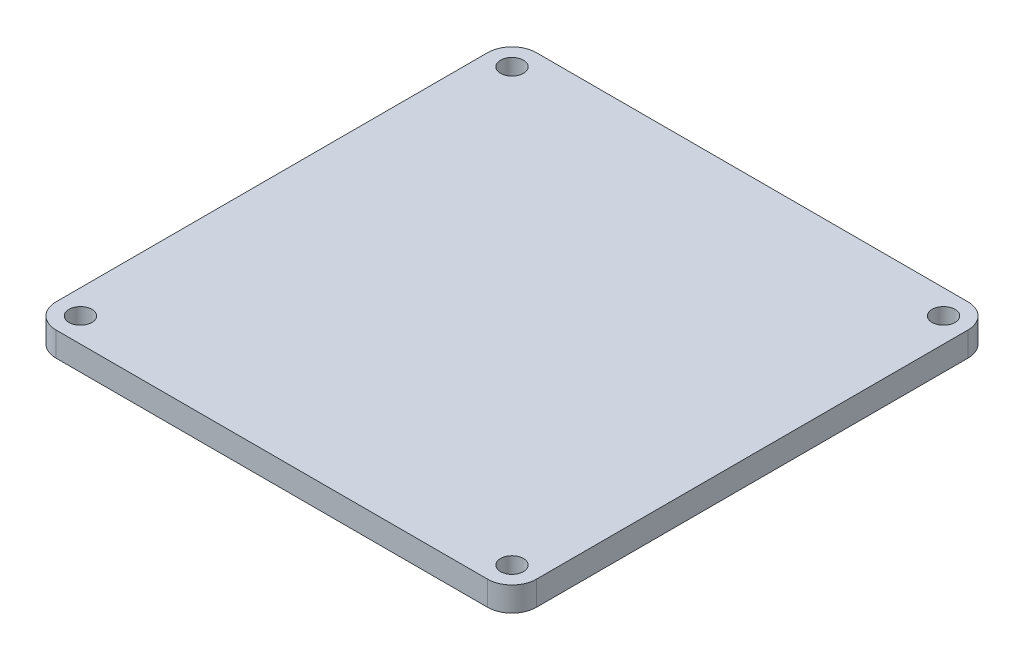
from build123d import *

# Parameters (mm, degrees)
BOSS_EXTRUDE2_DEPTH      = 5.08
BOSS_EXTRUDE2_DEPTH_BACK = 5.08
SKETCH1_R                = 4.7625


with BuildPart() as part:
    # Sketch1 → Boss-Extrude2 (new, two sides: drawn at the far end of the back side and taken through both)
    with BuildSketch(Plane(origin=(0, 0, 0), x_dir=(1, 0, 0), z_dir=(0, 1, 0)).offset(-BOSS_EXTRUDE2_DEPTH_BACK)):
        with BuildLine():
            Line((-89.802561211, 99.962561211), (89.802561211, 99.962561211))
            ThreePointArc((89.802561211, 99.962561211), (96.986766108, 96.986766108), (99.962561211, 89.802561211))
            Line((99.962561211, 89.802561211), (99.962561211, -89.802561211))
            ThreePointArc((99.962561211, -89.802561211), (96.986766108, -96.986766108), (89.802561211, -99.962561211))
            Line((89.802561211, -99.962561211), (-89.802561211, -99.962561211))
            ThreePointArc((-89.802561211, -99.962561211), (-96.986766108, -96.986766108), (-99.962561211, -89.802561211))
            Line((-99.962561211, -89.802561211), (-99.962561211, 89.802561211))
            ThreePointArc((-99.962561211, 89.802561211), (-96.986766108, 96.986766108), (-89.802561211, 99.962561211))
        make_face()
        with Locations((89.802561211, 89.802561211)):
            Circle(SKETCH1_R, mode=Mode.SUBTRACT)
        with Locations((89.802561211, -89.802561211)):
            Circle(SKETCH1_R, mode=Mode.SUBTRACT)
        with Locations((-89.802561211, -89.802561211)):
            Circle(SKETCH1_R, mode=Mode.SUBTRACT)
        with Locations((-89.802561211, 89.802561211)):
            Circle(SKETCH1_R, mode=Mode.SUBTRACT)
    extrude(amount=BOSS_EXTRUDE2_DEPTH + BOSS_EXTRUDE2_DEPTH_BACK)


solid = part.part
